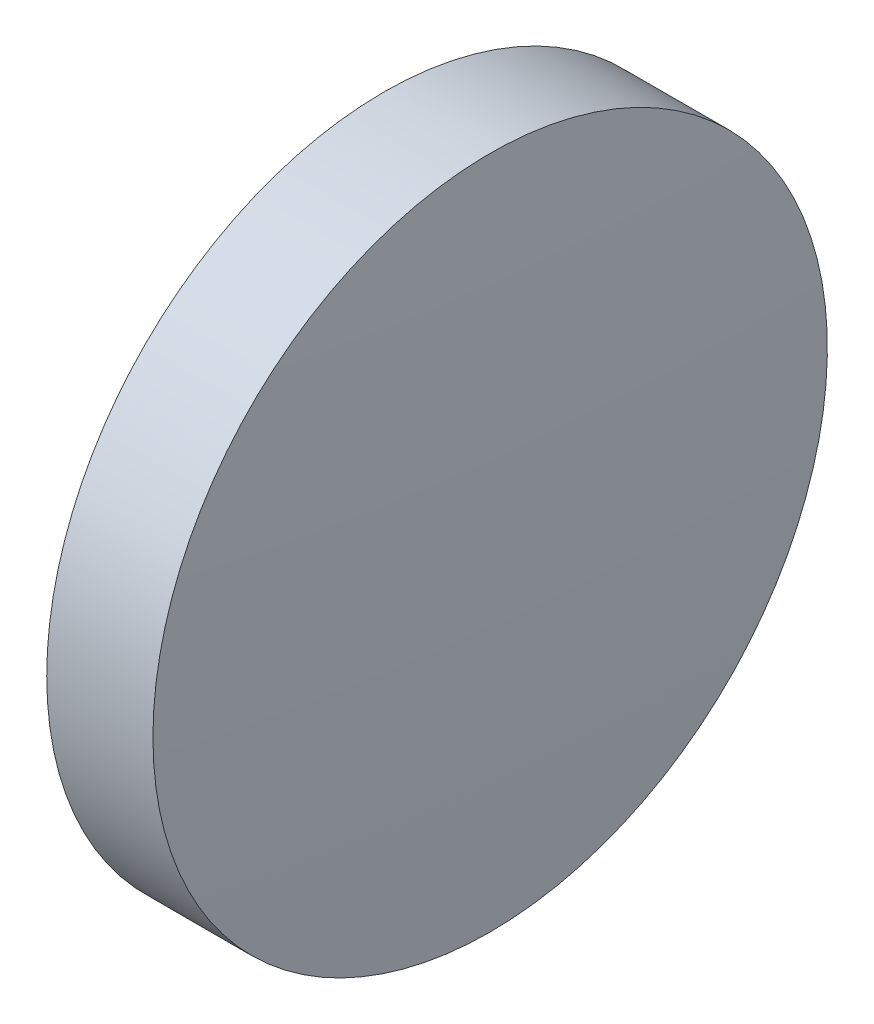
from build123d import *

# Parameters (mm, degrees)
SKETCH_1_ONE_SIDE_W = 2.000068571
SKETCH_1_ONE_SIDE_H = 6.35


with BuildPart() as part:
    # 草图1 one side → 旋转1 (revolve)
    with BuildSketch(Plane.XY, mode=Mode.PRIVATE) as revolve_1_sk:
        with Locations((43.229096888, 27.483056512)):
            Rectangle(SKETCH_1_ONE_SIDE_W, SKETCH_1_ONE_SIDE_H)
        with BuildLine():
            Line((42.029110173, 24.308056512), (42.229062602, 24.308056512))
            Line((42.229062602, 24.308056512), (42.229062602, 30.658056512))
            ThreePointArc((42.229062602, 30.658056512), (42.079110665, 27.484630176), (42.029110173, 24.308056512))
        make_face()
        with BuildLine():
            Line((44.229131173, 24.308056512), (44.429083602, 24.308056512))
            ThreePointArc((44.429083602, 24.308056512), (44.379083109, 27.484630176), (44.229131173, 30.658056512))
            Line((44.229131173, 30.658056512), (44.229131173, 24.308056512))
        make_face()
    revolve(revolve_1_sk.sketch.rotate(Axis((39.652700675, 24.308056512, 0), (1, 0, 0)), 90), axis=Axis((39.652700675, 24.308056512, 0), (1, 0, 0)))  # turned: the seam where the file's is


solid = part.part
